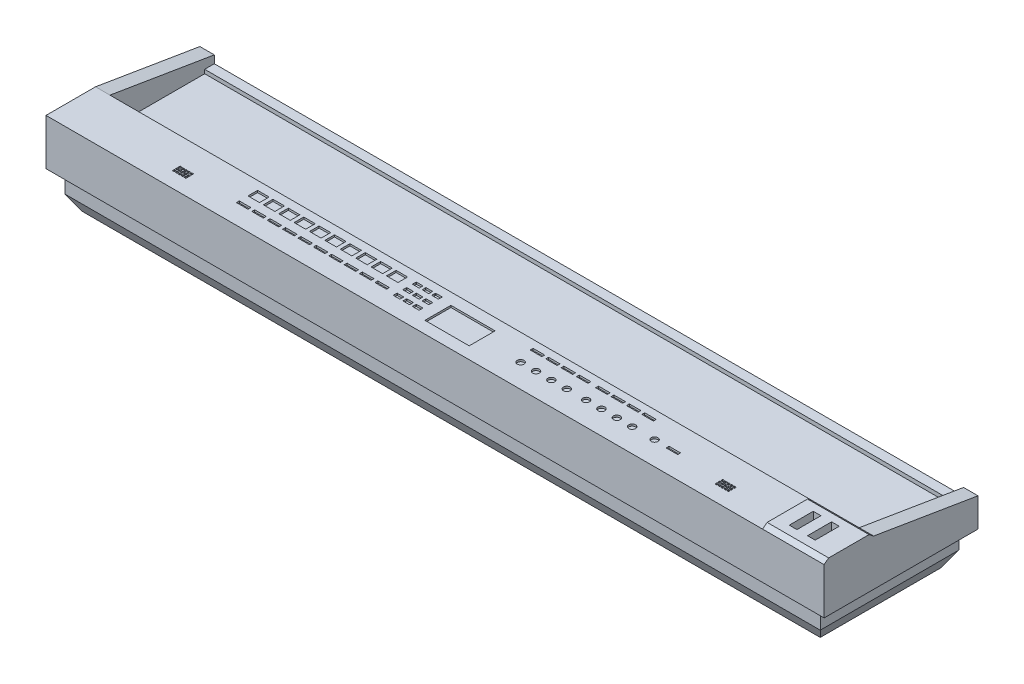
from build123d import *

# Parameters (mm, degrees)
BOSS_EXTRUDE1_DEPTH = 23.8125
BOSS_EXTRUDE2_DEPTH = 1236.6625
BOSS_EXTRUDE3_DEPTH = 23.8125
BOSS_EXTRUDE4_DEPTH = 101.6
BOSS_EXTRUDE5_DEPTH = 1246.1875
CUT_EXTRUDE1_DEPTH  = 242.3
SKETCH7_W           = 12.7
SKETCH7_H           = 39.6875
CUT_EXTRUDE2_DEPTH  = 25.796875
SKETCH8_R           = 5.55625
SKETCH8_W           = 19.05
SKETCH8_H           = 4.7625
CUT_EXTRUDE3_DEPTH  = 3.175
SKETCH9_W           = 73.025
SKETCH9_H           = 42.8625
CUT_EXTRUDE4_DEPTH  = 3.175
SKETCH10_W          = 11.1125
SKETCH10_H          = 6.35
CUT_EXTRUDE5_DEPTH  = 3.175
SKETCH11_W          = 19.05
SKETCH11_H          = 15.875
SKETCH11_H_2        = 4.7625
CUT_EXTRUDE6_DEPTH  = 3.175
SKETCH12_W          = 3.175
SKETCH12_H          = 3.175
CUT_EXTRUDE7_DEPTH  = 6.35
FILLET1_R           = 0.635


with BuildPart() as part:
    # Sketch1 → Boss-Extrude1 (new body)
    with BuildSketch(Plane(origin=(0, 0, 0), x_dir=(0, 0, -1), z_dir=(1, 0, 0))):
        Polygon((0, 0), (0, 47.625), (-172.271181571, 76.2), (-254, 76.2), (-254, 0), align=None)
    extrude(amount=BOSS_EXTRUDE1_DEPTH)

    # Sketch2 → Boss-Extrude2 (add)
    with BuildSketch(Plane.ZY):
        Polygon((0, 0), (0, 34.925), (15.875, 34.925), (15.875, 28.575), (172.271181571, 28.575), (172.271181571, 76.2), (254, 76.2), (254, 0), align=None)
    extrude(amount=BOSS_EXTRUDE2_DEPTH)

    # Sketch3 → Boss-Extrude3 (add)
    with BuildSketch(Plane.ZY.offset(1236.6625)):
        Polygon((0, 47.625), (0, 0), (254, 0), (254, 76.2), (172.271181571, 76.2), align=None)
    extrude(amount=BOSS_EXTRUDE3_DEPTH)

    # Sketch4 → Boss-Extrude4 (add)
    with BuildSketch(Plane(origin=(23.8125, 0, 0), x_dir=(0, 0, -1), z_dir=(1, 0, 0))):
        Polygon((-254, 76.2), (-246.473090786, 82.037059421), (-179.798090786, 82.037059421), (-172.271181571, 76.2), align=None)
    extrude(amount=-BOSS_EXTRUDE4_DEPTH)

    # Sketch5 → Boss-Extrude5 (add)
    with BuildSketch(Plane(origin=(4.7625, 0, 0), x_dir=(0, 0, -1), z_dir=(1, 0, 0))):
        Polygon((-241.3, 0), (-241.3, -33.3375), (-227.0125, -58.084175913), (-26.9875, -58.084175913), (-12.7, -33.3375), (-12.7, 0), align=None)
    extrude(amount=-BOSS_EXTRUDE5_DEPTH)

    # Sketch6 → Cut-Extrude1 (cut, through all)
    with BuildSketch(Plane(origin=(0, 0, 12.7), x_dir=(-1, 0, 0), z_dir=(0, 0, -1))):
        Polygon((9.525, -58.084175913), (-4.7625, -33.3375), (-4.7625, -58.084175913), align=None)
        Polygon((1241.425, -58.084175913), (1241.425, -33.3375), (1227.1375, -58.084175913), align=None)
    extrude(amount=-CUT_EXTRUDE1_DEPTH, mode=Mode.SUBTRACT)

    # Sketch7 → Cut-Extrude2 (cut)
    with BuildSketch(Plane(origin=(0, 82.037059421, 0), x_dir=(1, 0, 0), z_dir=(0, 1, 0))):
        with Locations((-19.05, -212.341840786)):
            Rectangle(SKETCH7_W, SKETCH7_H)
        with Locations((-49.2125, -212.341840786)):
            Rectangle(SKETCH7_W, SKETCH7_H)
    extrude(amount=-CUT_EXTRUDE2_DEPTH, mode=Mode.SUBTRACT)

    # Sketch8 → Cut-Extrude3 (cut)
    with BuildSketch(Plane(origin=(0, 76.2, 0), x_dir=(1, 0, 0), z_dir=(0, 1, 0))):
        with Locations((-331.7875, -215.133681571)):
            Circle(SKETCH8_R)
        with Locations((-357.1875, -215.133681571)):
            Circle(SKETCH8_R)
        with Locations((-382.5875, -215.133681571)):
            Circle(SKETCH8_R)
        with Locations((-407.9875, -215.133681571)):
            Circle(SKETCH8_R)
        with Locations((-439.7375, -215.133681571)):
            Circle(SKETCH8_R)
        with Locations((-465.1375, -215.133681571)):
            Circle(SKETCH8_R)
        with Locations((-490.5375, -215.133681571)):
            Circle(SKETCH8_R)
        with Locations((-515.9375, -215.133681571)):
            Circle(SKETCH8_R)
        with Locations((-294.9575, -215.133681571)):
            Circle(SKETCH8_R)
        with Locations((-331.7875, -187.352431571)):
            Rectangle(SKETCH8_W, SKETCH8_H)
        with Locations((-357.1875, -187.352431571)):
            Rectangle(SKETCH8_W, SKETCH8_H)
        with Locations((-382.5875, -187.352431571)):
            Rectangle(SKETCH8_W, SKETCH8_H)
        with Locations((-407.9875, -187.352431571)):
            Rectangle(SKETCH8_W, SKETCH8_H)
        with Locations((-439.7375, -187.352431571)):
            Rectangle(SKETCH8_W, SKETCH8_H)
        with Locations((-465.1375, -187.352431571)):
            Rectangle(SKETCH8_W, SKETCH8_H)
        with Locations((-490.5375, -187.352431571)):
            Rectangle(SKETCH8_W, SKETCH8_H)
        with Locations((-515.9375, -187.352431571)):
            Rectangle(SKETCH8_W, SKETCH8_H)
        with Locations((-263.8425, -215.133681571)):
            Rectangle(SKETCH8_W, SKETCH8_H)
    extrude(amount=-CUT_EXTRUDE3_DEPTH, mode=Mode.SUBTRACT)

    # Sketch9 → Cut-Extrude4 (cut)
    with BuildSketch(Plane(origin=(0, 76.2, 0), x_dir=(1, 0, 0), z_dir=(0, 1, 0))):
        with Locations((-618.33125, -212.752431571)):
            Rectangle(SKETCH9_W, SKETCH9_H)
    extrude(amount=-CUT_EXTRUDE4_DEPTH, mode=Mode.SUBTRACT)

    # Sketch10 → Cut-Extrude5 (cut)
    with BuildSketch(Plane(origin=(0, 76.2, 0), x_dir=(1, 0, 0), z_dir=(0, 1, 0))):
        with Locations((-679.45, -189.733681571)):
            Rectangle(SKETCH10_W, SKETCH10_H)
        with Locations((-695.325, -189.733681571)):
            Rectangle(SKETCH10_W, SKETCH10_H)
        with Locations((-711.2, -189.733681571)):
            Rectangle(SKETCH10_W, SKETCH10_H)
        with Locations((-711.2, -205.608681571)):
            Rectangle(SKETCH10_W, SKETCH10_H)
        with Locations((-695.325, -205.608681571)):
            Rectangle(SKETCH10_W, SKETCH10_H)
        with Locations((-679.45, -205.608681571)):
            Rectangle(SKETCH10_W, SKETCH10_H)
        with Locations((-679.45, -221.483681571)):
            Rectangle(SKETCH10_W, SKETCH10_H)
        with Locations((-695.325, -221.483681571)):
            Rectangle(SKETCH10_W, SKETCH10_H)
        with Locations((-711.2, -221.483681571)):
            Rectangle(SKETCH10_W, SKETCH10_H)
    extrude(amount=-CUT_EXTRUDE5_DEPTH, mode=Mode.SUBTRACT)

    # Sketch11 → Cut-Extrude6 (cut)
    with BuildSketch(Plane(origin=(0, 76.2, 0), x_dir=(1, 0, 0), z_dir=(0, 1, 0))):
        with Locations((-740.56875, -194.496181571)):
            Rectangle(SKETCH11_W, SKETCH11_H)
        with Locations((-740.56875, -219.102431571)):
            Rectangle(SKETCH11_W, SKETCH11_H_2)
        with Locations((-765.96875, -219.102431571)):
            Rectangle(SKETCH11_W, SKETCH11_H_2)
        with Locations((-765.96875, -194.496181571)):
            Rectangle(SKETCH11_W, SKETCH11_H)
        with Locations((-791.36875, -194.496181571)):
            Rectangle(SKETCH11_W, SKETCH11_H)
        with Locations((-791.36875, -219.102431571)):
            Rectangle(SKETCH11_W, SKETCH11_H_2)
        with Locations((-816.76875, -219.102431571)):
            Rectangle(SKETCH11_W, SKETCH11_H_2)
        with Locations((-816.76875, -194.496181571)):
            Rectangle(SKETCH11_W, SKETCH11_H)
        with Locations((-842.16875, -194.496181571)):
            Rectangle(SKETCH11_W, SKETCH11_H)
        with Locations((-842.16875, -219.102431571)):
            Rectangle(SKETCH11_W, SKETCH11_H_2)
        with Locations((-867.56875, -219.102431571)):
            Rectangle(SKETCH11_W, SKETCH11_H_2)
        with Locations((-867.56875, -194.496181571)):
            Rectangle(SKETCH11_W, SKETCH11_H)
        with Locations((-892.96875, -194.496181571)):
            Rectangle(SKETCH11_W, SKETCH11_H)
        with Locations((-892.96875, -219.102431571)):
            Rectangle(SKETCH11_W, SKETCH11_H_2)
        with Locations((-918.36875, -219.102431571)):
            Rectangle(SKETCH11_W, SKETCH11_H_2)
        with Locations((-918.36875, -194.496181571)):
            Rectangle(SKETCH11_W, SKETCH11_H)
        with Locations((-943.76875, -194.496181571)):
            Rectangle(SKETCH11_W, SKETCH11_H)
        with Locations((-943.76875, -219.102431571)):
            Rectangle(SKETCH11_W, SKETCH11_H_2)
        with Locations((-969.16875, -219.102431571)):
            Rectangle(SKETCH11_W, SKETCH11_H_2)
        with Locations((-969.16875, -194.496181571)):
            Rectangle(SKETCH11_W, SKETCH11_H)
    extrude(amount=-CUT_EXTRUDE6_DEPTH, mode=Mode.SUBTRACT)

    # Sketch12 → Cut-Extrude7 (cut)
    with BuildSketch(Plane(origin=(0, 76.2, 0), x_dir=(1, 0, 0), z_dir=(0, 1, 0))):
        with Locations((-160.9725, -217.4875)):
            Rectangle(SKETCH12_W, SKETCH12_H)
        with Locations((-160.9725, -222.25)):
            Rectangle(SKETCH12_W, SKETCH12_H)
        with Locations((-160.9725, -227.0125)):
            Rectangle(SKETCH12_W, SKETCH12_H)
        with Locations((-165.735, -217.4875)):
            Rectangle(SKETCH12_W, SKETCH12_H)
        with Locations((-170.4975, -217.4875)):
            Rectangle(SKETCH12_W, SKETCH12_H)
        with Locations((-175.26, -217.4875)):
            Rectangle(SKETCH12_W, SKETCH12_H)
        with Locations((-180.0225, -217.4875)):
            Rectangle(SKETCH12_W, SKETCH12_H)
        with Locations((-165.735, -222.25)):
            Rectangle(SKETCH12_W, SKETCH12_H)
        with Locations((-170.4975, -222.25)):
            Rectangle(SKETCH12_W, SKETCH12_H)
        with Locations((-175.26, -222.25)):
            Rectangle(SKETCH12_W, SKETCH12_H)
        with Locations((-180.0225, -222.25)):
            Rectangle(SKETCH12_W, SKETCH12_H)
        with Locations((-165.735, -227.0125)):
            Rectangle(SKETCH12_W, SKETCH12_H)
        with Locations((-170.4975, -227.0125)):
            Rectangle(SKETCH12_W, SKETCH12_H)
        with Locations((-175.26, -227.0125)):
            Rectangle(SKETCH12_W, SKETCH12_H)
        with Locations((-180.0225, -227.0125)):
            Rectangle(SKETCH12_W, SKETCH12_H)
        with Locations((-1056.64, -227.0125)):
            Rectangle(SKETCH12_W, SKETCH12_H)
        with Locations((-1061.4025, -227.0125)):
            Rectangle(SKETCH12_W, SKETCH12_H)
        with Locations((-1066.165, -227.0125)):
            Rectangle(SKETCH12_W, SKETCH12_H)
        with Locations((-1070.9275, -227.0125)):
            Rectangle(SKETCH12_W, SKETCH12_H)
        with Locations((-1056.64, -222.25)):
            Rectangle(SKETCH12_W, SKETCH12_H)
        with Locations((-1061.4025, -222.25)):
            Rectangle(SKETCH12_W, SKETCH12_H)
        with Locations((-1066.165, -222.25)):
            Rectangle(SKETCH12_W, SKETCH12_H)
        with Locations((-1070.9275, -222.25)):
            Rectangle(SKETCH12_W, SKETCH12_H)
        with Locations((-1056.64, -217.4875)):
            Rectangle(SKETCH12_W, SKETCH12_H)
        with Locations((-1061.4025, -217.4875)):
            Rectangle(SKETCH12_W, SKETCH12_H)
        with Locations((-1066.165, -217.4875)):
            Rectangle(SKETCH12_W, SKETCH12_H)
        with Locations((-1070.9275, -217.4875)):
            Rectangle(SKETCH12_W, SKETCH12_H)
        with Locations((-1075.69, -227.0125)):
            Rectangle(SKETCH12_W, SKETCH12_H)
        with Locations((-1075.69, -222.25)):
            Rectangle(SKETCH12_W, SKETCH12_H)
        with Locations((-1075.69, -217.4875)):
            Rectangle(SKETCH12_W, SKETCH12_H)
    extrude(amount=-CUT_EXTRUDE7_DEPTH, mode=Mode.SUBTRACT)

    # Fillet1
    fillet1_edges = [part.edges().sort_by_distance(p)[0] for p in [
        (-689.76875, 74.6125, 186.558681571),
        (-689.76875, 74.6125, 192.908681571),
        (-700.88125, 74.6125, 192.908681571),
        (-700.88125, 74.6125, 186.558681571),
        (-705.64375, 74.6125, 186.558681571),
        (-705.64375, 74.6125, 192.908681571),
        (-716.75625, 74.6125, 192.908681571),
        (-716.75625, 74.6125, 186.558681571),
        (-705.64375, 74.6125, 208.783681571),
        (-716.75625, 74.6125, 208.783681571),
        (-716.75625, 74.6125, 202.433681571),
        (-705.64375, 74.6125, 202.433681571),
        (-689.76875, 74.6125, 208.783681571),
        (-700.88125, 74.6125, 208.783681571),
        (-700.88125, 74.6125, 202.433681571),
        (-689.76875, 74.6125, 202.433681571),
        (-673.89375, 74.6125, 208.783681571),
        (-685.00625, 74.6125, 208.783681571),
        (-685.00625, 74.6125, 202.433681571),
        (-673.89375, 74.6125, 202.433681571),
        (-673.89375, 74.6125, 218.308681571),
        (-673.89375, 74.6125, 224.658681571),
        (-685.00625, 74.6125, 224.658681571),
        (-685.00625, 74.6125, 218.308681571),
        (-689.76875, 74.6125, 218.308681571),
        (-689.76875, 74.6125, 224.658681571),
        (-700.88125, 74.6125, 224.658681571),
        (-700.88125, 74.6125, 218.308681571),
        (-705.64375, 74.6125, 218.308681571),
        (-705.64375, 74.6125, 224.658681571),
        (-716.75625, 74.6125, 224.658681571),
        (-716.75625, 74.6125, 218.308681571),
        (-673.89375, 74.6125, 186.558681571),
        (-673.89375, 74.6125, 192.908681571),
        (-685.00625, 74.6125, 192.908681571),
        (-685.00625, 74.6125, 186.558681571),
    ]]
    fillet(fillet1_edges, radius=FILLET1_R)


solid = part.part
